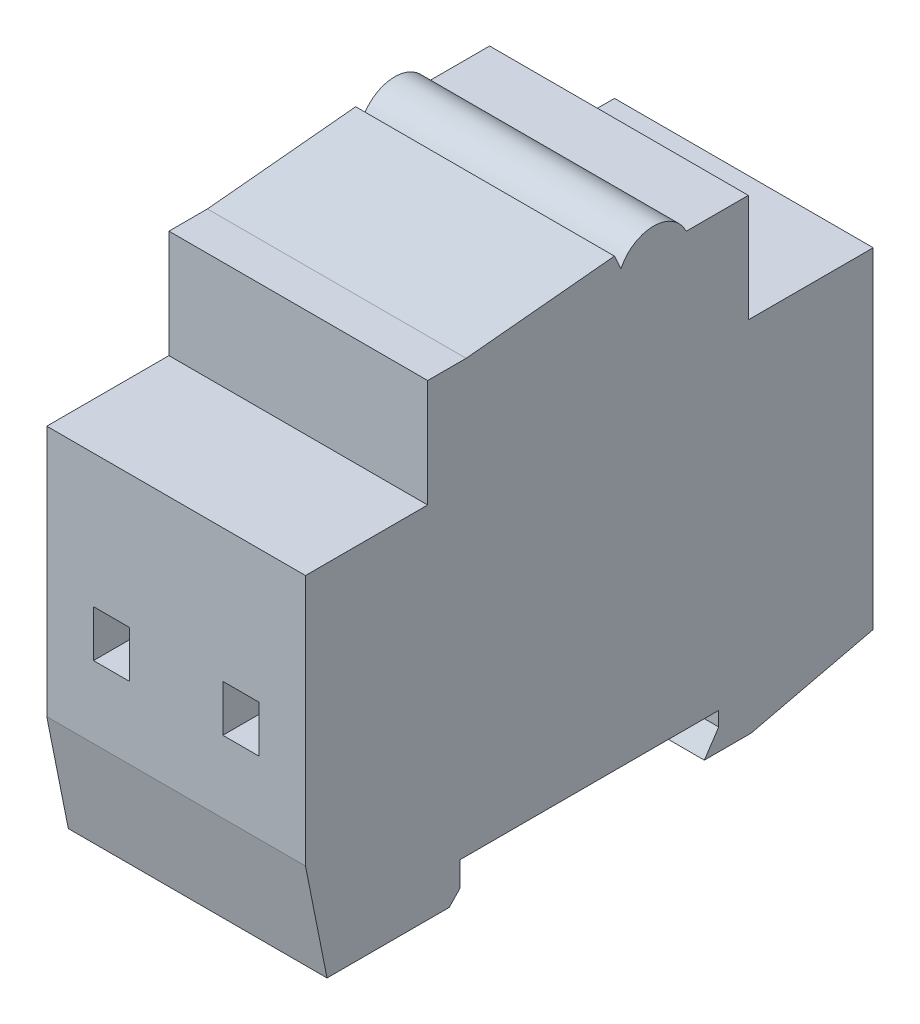
from build123d import *

# Parameters (mm, degrees)
EXTRUDE_1_DEPTH     = 36
SKETCH_2_W          = 5
SKETCH_2_H          = 6.5
CUT_EXTRUDE_1_DEPTH = 20
SKETCH_3_W          = 5
SKETCH_3_H          = 6.5
CUT_EXTRUDE_2_DEPTH = 20


with BuildPart() as part:
    # Эскиз1 → Бобышка-Вытянуть1 (new body)
    with BuildSketch(Plane(origin=(0, 0, 0), x_dir=(0, 0, -1), z_dir=(1, 0, 0))):
        with BuildLine():
            Line((0, 15), (3, 0))
            Line((3, 0), (20, 0))
            Line((20, 0), (21.5, 1.565195477))
            Line((21.5, 1.565195477), (21.5, 5))
            Line((21.5, 5), (57.5, 5))
            Line((57.5, 5), (57.5, 3))
            Line((57.5, 3), (55.5, 0))
            Line((55.5, 0), (62, 0))
            Line((62, 0), (79, 4))
            Line((79, 4), (79, 50))
            Line((79, 50), (61.619424271, 50))
            Line((61.619424271, 50), (61.619424271, 65))
            Line((61.619424271, 65), (52.96803048, 65))
            ThreePointArc((52.96803048, 65), (48.430063355, 67.893872917), (43.892096231, 65))
            Line((43.892096231, 65), (42.98652577, 67))
            Line((42.98652577, 67), (22.355935477, 65))
            Line((22.355935477, 65), (17, 65))
            Line((17, 65), (17, 50))
            Line((17, 50), (0, 50))
            Line((0, 50), (0, 15))
        make_face()
    extrude(amount=EXTRUDE_1_DEPTH)

    # Эскиз2 → Вырез-Вытянуть1 (cut)
    with BuildSketch(Plane(origin=(0, 0, -79), x_dir=(-1, 0, 0), z_dir=(0, 0, -1))):
        with Locations((-27, 28.25)):
            Rectangle(SKETCH_2_W, SKETCH_2_H)
        with Locations((-9, 28.25)):
            Rectangle(SKETCH_2_W, SKETCH_2_H)
    extrude(amount=-CUT_EXTRUDE_1_DEPTH, mode=Mode.SUBTRACT)

    # Эскиз3 → Вырез-Вытянуть2 (cut)
    with BuildSketch(Plane.XY):
        with Locations((9, 28.25)):
            Rectangle(SKETCH_3_W, SKETCH_3_H)
        with Locations((27, 28.25)):
            Rectangle(SKETCH_3_W, SKETCH_3_H)
    extrude(amount=-CUT_EXTRUDE_2_DEPTH, mode=Mode.SUBTRACT)


solid = part.part
